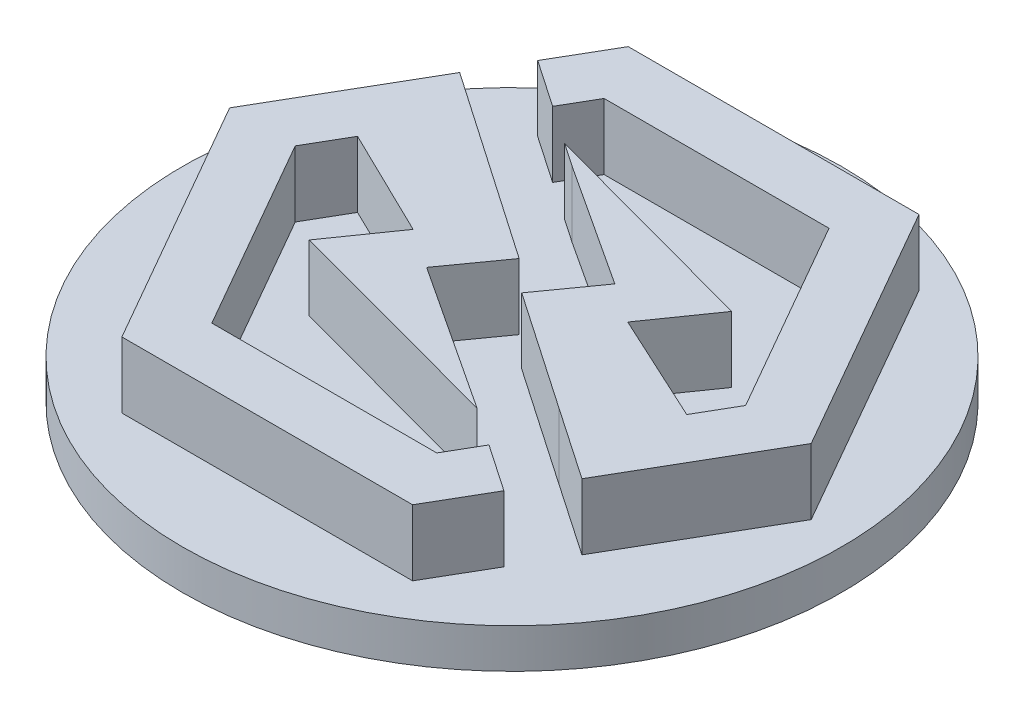
from build123d import *

# Parameters (mm, degrees)
SKIZZE2_R                       = 25
AUFSATZ_LINEAR_AUSTRAGEN2_DEPTH = 3
AUFSATZ_LINEAR_AUSTRAGEN1_DEPTH = 5


with BuildPart() as part:
    # Skizze2 → Aufsatz-Linear austragen2 (new body)
    with BuildSketch(Plane(origin=(0, 0, 0), x_dir=(1, 0, 0), z_dir=(0, 1, 0))):
        Circle(SKIZZE2_R)
    extrude(amount=AUFSATZ_LINEAR_AUSTRAGEN2_DEPTH)

    # Model → Aufsatz-Linear austragen1 (add)
    with BuildSketch(Plane(origin=(0, 3, -3), x_dir=(1, 0, 0), z_dir=(0, -1, 0))):
        Polygon((-4.104544089, 5.371303079), (-1.178372214, 1.279701516), (-15.653137839, -8.684400046), (-22.055559714, 2.361810891), (-11.094544089, 21.499584329), (10.959909036, 21.497357766), (13.499830911, 17.115131204), (9.924205911, 14.669310891), (8.470377786, 17.177592141), (-8.590481589, 17.179349954), (-17.069700339, 2.374701516), (-15.335325339, -0.617798484), (-7.115325339, 3.386615579), (-10.358840964, 8.025599954), (7.050534036, 12.703842141), align=None)
        Polygon((15.672018411, 13.367240579), (10.169830911, 9.603646829), (1.176393411, 3.438998391), (4.118971536, -0.680845359), (-5.261184714, -6.810220359), (-7.008684714, -8.005532859), (10.356862161, -3.306900046), (7.113346536, 1.332084329), (15.428268411, 5.173021829), (17.067721536, 2.344232766), (8.588502786, -12.460650046), (-8.472356589, -12.458657859), (-9.905090964, -9.986704734), (-13.480715964, -12.432525046), (-10.961887839, -16.778423484), (11.092565286, -16.780884421), (22.053346536, 2.357123391), align=None)
    extrude(amount=-AUFSATZ_LINEAR_AUSTRAGEN1_DEPTH)


solid = part.part
